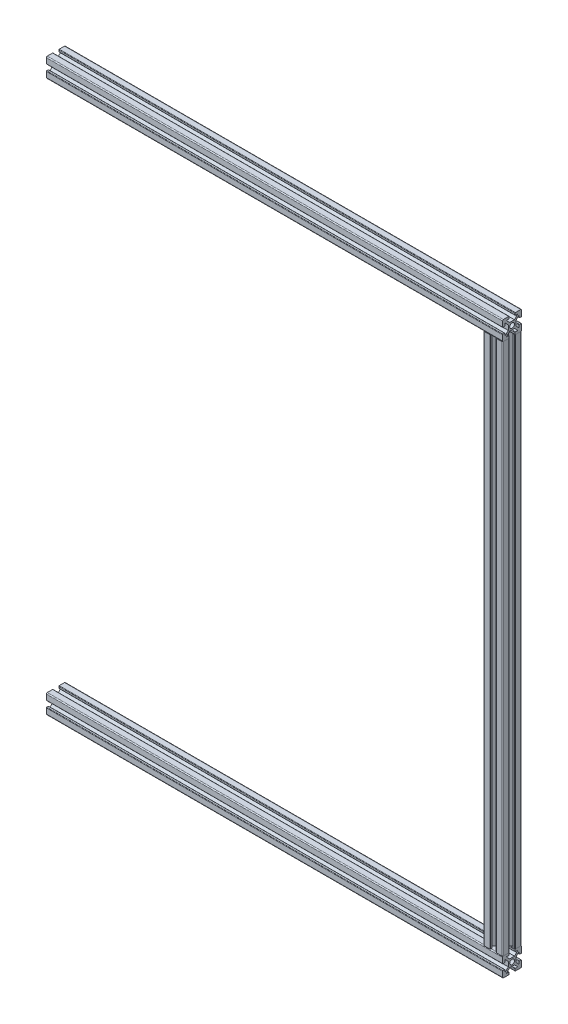
from build123d import *

# Parameters (mm, degrees)
SKETCH11_R                              = 2.5
ALUMINIUM_PROF_ALUMINIUM_PROF_1_DEPTH   = 470
SKETCH11_ON_SEGMENT_2_R                 = 2.5
ALUMINIUM_PROF_ALUMINIUM_PROF_1_2_DEPTH = 580
SKETCH11_ON_SEGMENT_3_R                 = 2.5
ALUMINIUM_PROF_ALUMINIUM_PROF_1_3_DEPTH = 470
PART_START                              = 470
PART_RUN_ON_DEPTH                       = 11.535534
BODY_3_RUN_ON_DEPTH                     = 11.535534


with BuildPart() as part:
    # Sketch11 → Aluminium prof ALUMINIUM PROF(1) (new body)
    with BuildSketch(Plane(origin=(-195.421052632, 179.342105263, 0), x_dir=(0, 1, 0), z_dir=(1, 0, 0))):
        with BuildLine():
            Line((-2.5, 4), (2.5, 4))
            Line((2.5, 4), (6.035533906, 7.535533906))
            Line((6.035533906, 7.535533906), (3.535533906, 7.535533906))
            ThreePointArc((3.535533906, 7.535533906), (3.181980515, 7.681980515), (3.035533906, 8.035533906))
            Line((3.035533906, 8.035533906), (3.035533906, 9.535533906))
            ThreePointArc((3.035533906, 9.535533906), (3.181980515, 9.889087297), (3.535533906, 10.035533906))
            Line((3.535533906, 10.035533906), (9.035533906, 10.035533906))
            ThreePointArc((9.035533906, 10.035533906), (9.742640687, 9.742640687), (10.035533906, 9.035533906))
            Line((10.035533906, 9.035533906), (10.035533906, 3.535533906))
            ThreePointArc((10.035533906, 3.535533906), (9.889087297, 3.181980515), (9.535533906, 3.035533906))
            Line((9.535533906, 3.035533906), (8.035533906, 3.035533906))
            ThreePointArc((8.035533906, 3.035533906), (7.681980515, 3.181980515), (7.535533906, 3.535533906))
            Line((7.535533906, 3.535533906), (7.535533906, 6.035533906))
            Line((7.535533906, 6.035533906), (4, 2.5))
            Line((4, 2.5), (4, -2.5))
            Line((4, -2.5), (7.535533906, -6.035533906))
            Line((7.535533906, -6.035533906), (7.535533906, -3.535533906))
            ThreePointArc((7.535533906, -3.535533906), (7.681980515, -3.181980515), (8.035533906, -3.035533906))
            Line((8.035533906, -3.035533906), (9.535533906, -3.035533906))
            ThreePointArc((9.535533906, -3.035533906), (9.889087297, -3.181980515), (10.035533906, -3.535533906))
            Line((10.035533906, -3.535533906), (10.035533906, -9.035533906))
            ThreePointArc((10.035533906, -9.035533906), (9.742640687, -9.742640687), (9.035533906, -10.035533906))
            Line((9.035533906, -10.035533906), (3.535533906, -10.035533906))
            ThreePointArc((3.535533906, -10.035533906), (3.181980515, -9.889087297), (3.035533906, -9.535533906))
            Line((3.035533906, -9.535533906), (3.035533906, -8.035533906))
            ThreePointArc((3.035533906, -8.035533906), (3.181980515, -7.681980515), (3.535533906, -7.535533906))
            Line((3.535533906, -7.535533906), (6.035533906, -7.535533906))
            Line((6.035533906, -7.535533906), (2.5, -4))
            Line((2.5, -4), (-2.5, -4))
            Line((-2.5, -4), (-6.035533906, -7.535533906))
            Line((-6.035533906, -7.535533906), (-3.535533906, -7.535533906))
            ThreePointArc((-3.535533906, -7.535533906), (-3.181980515, -7.681980515), (-3.035533906, -8.035533906))
            Line((-3.035533906, -8.035533906), (-3.035533906, -9.535533906))
            ThreePointArc((-3.035533906, -9.535533906), (-3.181980515, -9.889087297), (-3.535533906, -10.035533906))
            Line((-3.535533906, -10.035533906), (-9.035533906, -10.035533906))
            ThreePointArc((-9.035533906, -10.035533906), (-9.742640687, -9.742640687), (-10.035533906, -9.035533906))
            Line((-10.035533906, -9.035533906), (-10.035533906, -3.535533906))
            ThreePointArc((-10.035533906, -3.535533906), (-9.889087297, -3.181980515), (-9.535533906, -3.035533906))
            Line((-9.535533906, -3.035533906), (-8.035533906, -3.035533906))
            ThreePointArc((-8.035533906, -3.035533906), (-7.681980515, -3.181980515), (-7.535533906, -3.535533906))
            Line((-7.535533906, -3.535533906), (-7.535533906, -6.035533906))
            Line((-7.535533906, -6.035533906), (-4, -2.5))
            Line((-4, -2.5), (-4, 2.5))
            Line((-4, 2.5), (-7.535533906, 6.035533906))
            Line((-7.535533906, 6.035533906), (-7.535533906, 3.535533906))
            ThreePointArc((-7.535533906, 3.535533906), (-7.681980515, 3.181980515), (-8.035533906, 3.035533906))
            Line((-8.035533906, 3.035533906), (-9.535533906, 3.035533906))
            ThreePointArc((-9.535533906, 3.035533906), (-9.889087297, 3.181980515), (-10.035533906, 3.535533906))
            Line((-10.035533906, 3.535533906), (-10.035533906, 9.035533906))
            ThreePointArc((-10.035533906, 9.035533906), (-9.742640687, 9.742640687), (-9.035533906, 10.035533906))
            Line((-9.035533906, 10.035533906), (-3.535533906, 10.035533906))
            ThreePointArc((-3.535533906, 10.035533906), (-3.181980515, 9.889087297), (-3.035533906, 9.535533906))
            Line((-3.035533906, 9.535533906), (-3.035533906, 8.035533906))
            ThreePointArc((-3.035533906, 8.035533906), (-3.181980515, 7.681980515), (-3.535533906, 7.535533906))
            Line((-3.535533906, 7.535533906), (-6.035533906, 7.535533906))
            Line((-6.035533906, 7.535533906), (-2.5, 4))
        make_face()
        Circle(SKETCH11_R, mode=Mode.SUBTRACT)
    extrude(amount=ALUMINIUM_PROF_ALUMINIUM_PROF_1_DEPTH)

    # Sketch11 → part run on (add)
    with BuildSketch(Plane(origin=(-195.421052632, 179.342105263, 0), x_dir=(0, 1, 0), z_dir=(1, 0, 0)).offset(PART_START)):
        with BuildLine():
            Line((-2.5, 4), (2.5, 4))
            Line((2.5, 4), (6.035533906, 7.535533906))
            Line((6.035533906, 7.535533906), (3.535533906, 7.535533906))
            ThreePointArc((3.535533906, 7.535533906), (3.181980515, 7.681980515), (3.035533906, 8.035533906))
            Line((3.035533906, 8.035533906), (3.035533906, 9.535533906))
            ThreePointArc((3.035533906, 9.535533906), (3.181980515, 9.889087297), (3.535533906, 10.035533906))
            Line((3.535533906, 10.035533906), (9.035533906, 10.035533906))
            ThreePointArc((9.035533906, 10.035533906), (9.742640687, 9.742640687), (10.035533906, 9.035533906))
            Line((10.035533906, 9.035533906), (10.035533906, 3.535533906))
            ThreePointArc((10.035533906, 3.535533906), (9.889087297, 3.181980515), (9.535533906, 3.035533906))
            Line((9.535533906, 3.035533906), (8.035533906, 3.035533906))
            ThreePointArc((8.035533906, 3.035533906), (7.681980515, 3.181980515), (7.535533906, 3.535533906))
            Line((7.535533906, 3.535533906), (7.535533906, 6.035533906))
            Line((7.535533906, 6.035533906), (4, 2.5))
            Line((4, 2.5), (4, -2.5))
            Line((4, -2.5), (7.535533906, -6.035533906))
            Line((7.535533906, -6.035533906), (7.535533906, -3.535533906))
            ThreePointArc((7.535533906, -3.535533906), (7.681980515, -3.181980515), (8.035533906, -3.035533906))
            Line((8.035533906, -3.035533906), (9.535533906, -3.035533906))
            ThreePointArc((9.535533906, -3.035533906), (9.889087297, -3.181980515), (10.035533906, -3.535533906))
            Line((10.035533906, -3.535533906), (10.035533906, -9.035533906))
            ThreePointArc((10.035533906, -9.035533906), (9.742640687, -9.742640687), (9.035533906, -10.035533906))
            Line((9.035533906, -10.035533906), (3.535533906, -10.035533906))
            ThreePointArc((3.535533906, -10.035533906), (3.181980515, -9.889087297), (3.035533906, -9.535533906))
            Line((3.035533906, -9.535533906), (3.035533906, -8.035533906))
            ThreePointArc((3.035533906, -8.035533906), (3.181980515, -7.681980515), (3.535533906, -7.535533906))
            Line((3.535533906, -7.535533906), (6.035533906, -7.535533906))
            Line((6.035533906, -7.535533906), (2.5, -4))
            Line((2.5, -4), (-2.5, -4))
            Line((-2.5, -4), (-6.035533906, -7.535533906))
            Line((-6.035533906, -7.535533906), (-3.535533906, -7.535533906))
            ThreePointArc((-3.535533906, -7.535533906), (-3.181980515, -7.681980515), (-3.035533906, -8.035533906))
            Line((-3.035533906, -8.035533906), (-3.035533906, -9.535533906))
            ThreePointArc((-3.035533906, -9.535533906), (-3.181980515, -9.889087297), (-3.535533906, -10.035533906))
            Line((-3.535533906, -10.035533906), (-9.035533906, -10.035533906))
            ThreePointArc((-9.035533906, -10.035533906), (-9.742640687, -9.742640687), (-10.035533906, -9.035533906))
            Line((-10.035533906, -9.035533906), (-10.035533906, -3.535533906))
            ThreePointArc((-10.035533906, -3.535533906), (-9.889087297, -3.181980515), (-9.535533906, -3.035533906))
            Line((-9.535533906, -3.035533906), (-8.035533906, -3.035533906))
            ThreePointArc((-8.035533906, -3.035533906), (-7.681980515, -3.181980515), (-7.535533906, -3.535533906))
            Line((-7.535533906, -3.535533906), (-7.535533906, -6.035533906))
            Line((-7.535533906, -6.035533906), (-4, -2.5))
            Line((-4, -2.5), (-4, 2.5))
            Line((-4, 2.5), (-7.535533906, 6.035533906))
            Line((-7.535533906, 6.035533906), (-7.535533906, 3.535533906))
            ThreePointArc((-7.535533906, 3.535533906), (-7.681980515, 3.181980515), (-8.035533906, 3.035533906))
            Line((-8.035533906, 3.035533906), (-9.535533906, 3.035533906))
            ThreePointArc((-9.535533906, 3.035533906), (-9.889087297, 3.181980515), (-10.035533906, 3.535533906))
            Line((-10.035533906, 3.535533906), (-10.035533906, 9.035533906))
            ThreePointArc((-10.035533906, 9.035533906), (-9.742640687, 9.742640687), (-9.035533906, 10.035533906))
            Line((-9.035533906, 10.035533906), (-3.535533906, 10.035533906))
            ThreePointArc((-3.535533906, 10.035533906), (-3.181980515, 9.889087297), (-3.035533906, 9.535533906))
            Line((-3.035533906, 9.535533906), (-3.035533906, 8.035533906))
            ThreePointArc((-3.035533906, 8.035533906), (-3.181980515, 7.681980515), (-3.535533906, 7.535533906))
            Line((-3.535533906, 7.535533906), (-6.035533906, 7.535533906))
            Line((-6.035533906, 7.535533906), (-2.5, 4))
        make_face()
        Circle(SKETCH11_R, mode=Mode.SUBTRACT)
    extrude(amount=PART_RUN_ON_DEPTH)

    # Trim_Extend1 6
    split(bisect_by=Plane(origin=(284.614481274, -110.657894737, 6.285533906), x_dir=(0, -1, 0), z_dir=(-1, 0, 0)), keep=Keep.TOP)


with BuildPart() as body_2:
    # Sketch11 on segment 2 (carried to segment 2) → Aluminium prof ALUMINIUM PROF_1 2 (new body)
    with BuildSketch(Plane(origin=(274.578947368, 179.342105263, 0), x_dir=(1, 0, 0), z_dir=(0, -1, 0))):
        with BuildLine():
            Line((-2.5, 4), (2.5, 4))
            Line((2.5, 4), (6.035533906, 7.535533906))
            Line((6.035533906, 7.535533906), (3.535533906, 7.535533906))
            ThreePointArc((3.535533906, 7.535533906), (3.181980515, 7.681980515), (3.035533906, 8.035533906))
            Line((3.035533906, 8.035533906), (3.035533906, 9.535533906))
            ThreePointArc((3.035533906, 9.535533906), (3.181980515, 9.889087297), (3.535533906, 10.035533906))
            Line((3.535533906, 10.035533906), (9.035533906, 10.035533906))
            ThreePointArc((9.035533906, 10.035533906), (9.742640687, 9.742640687), (10.035533906, 9.035533906))
            Line((10.035533906, 9.035533906), (10.035533906, 3.535533906))
            ThreePointArc((10.035533906, 3.535533906), (9.889087297, 3.181980515), (9.535533906, 3.035533906))
            Line((9.535533906, 3.035533906), (8.035533906, 3.035533906))
            ThreePointArc((8.035533906, 3.035533906), (7.681980515, 3.181980515), (7.535533906, 3.535533906))
            Line((7.535533906, 3.535533906), (7.535533906, 6.035533906))
            Line((7.535533906, 6.035533906), (4, 2.5))
            Line((4, 2.5), (4, -2.5))
            Line((4, -2.5), (7.535533906, -6.035533906))
            Line((7.535533906, -6.035533906), (7.535533906, -3.535533906))
            ThreePointArc((7.535533906, -3.535533906), (7.681980515, -3.181980515), (8.035533906, -3.035533906))
            Line((8.035533906, -3.035533906), (9.535533906, -3.035533906))
            ThreePointArc((9.535533906, -3.035533906), (9.889087297, -3.181980515), (10.035533906, -3.535533906))
            Line((10.035533906, -3.535533906), (10.035533906, -9.035533906))
            ThreePointArc((10.035533906, -9.035533906), (9.742640687, -9.742640687), (9.035533906, -10.035533906))
            Line((9.035533906, -10.035533906), (3.535533906, -10.035533906))
            ThreePointArc((3.535533906, -10.035533906), (3.181980515, -9.889087297), (3.035533906, -9.535533906))
            Line((3.035533906, -9.535533906), (3.035533906, -8.035533906))
            ThreePointArc((3.035533906, -8.035533906), (3.181980515, -7.681980515), (3.535533906, -7.535533906))
            Line((3.535533906, -7.535533906), (6.035533906, -7.535533906))
            Line((6.035533906, -7.535533906), (2.5, -4))
            Line((2.5, -4), (-2.5, -4))
            Line((-2.5, -4), (-6.035533906, -7.535533906))
            Line((-6.035533906, -7.535533906), (-3.535533906, -7.535533906))
            ThreePointArc((-3.535533906, -7.535533906), (-3.181980515, -7.681980515), (-3.035533906, -8.035533906))
            Line((-3.035533906, -8.035533906), (-3.035533906, -9.535533906))
            ThreePointArc((-3.035533906, -9.535533906), (-3.181980515, -9.889087297), (-3.535533906, -10.035533906))
            Line((-3.535533906, -10.035533906), (-9.035533906, -10.035533906))
            ThreePointArc((-9.035533906, -10.035533906), (-9.742640687, -9.742640687), (-10.035533906, -9.035533906))
            Line((-10.035533906, -9.035533906), (-10.035533906, -3.535533906))
            ThreePointArc((-10.035533906, -3.535533906), (-9.889087297, -3.181980515), (-9.535533906, -3.035533906))
            Line((-9.535533906, -3.035533906), (-8.035533906, -3.035533906))
            ThreePointArc((-8.035533906, -3.035533906), (-7.681980515, -3.181980515), (-7.535533906, -3.535533906))
            Line((-7.535533906, -3.535533906), (-7.535533906, -6.035533906))
            Line((-7.535533906, -6.035533906), (-4, -2.5))
            Line((-4, -2.5), (-4, 2.5))
            Line((-4, 2.5), (-7.535533906, 6.035533906))
            Line((-7.535533906, 6.035533906), (-7.535533906, 3.535533906))
            ThreePointArc((-7.535533906, 3.535533906), (-7.681980515, 3.181980515), (-8.035533906, 3.035533906))
            Line((-8.035533906, 3.035533906), (-9.535533906, 3.035533906))
            ThreePointArc((-9.535533906, 3.035533906), (-9.889087297, 3.181980515), (-10.035533906, 3.535533906))
            Line((-10.035533906, 3.535533906), (-10.035533906, 9.035533906))
            ThreePointArc((-10.035533906, 9.035533906), (-9.742640687, 9.742640687), (-9.035533906, 10.035533906))
            Line((-9.035533906, 10.035533906), (-3.535533906, 10.035533906))
            ThreePointArc((-3.535533906, 10.035533906), (-3.181980515, 9.889087297), (-3.035533906, 9.535533906))
            Line((-3.035533906, 9.535533906), (-3.035533906, 8.035533906))
            ThreePointArc((-3.035533906, 8.035533906), (-3.181980515, 7.681980515), (-3.535533906, 7.535533906))
            Line((-3.535533906, 7.535533906), (-6.035533906, 7.535533906))
            Line((-6.035533906, 7.535533906), (-2.5, 4))
        make_face()
        Circle(SKETCH11_ON_SEGMENT_2_R, mode=Mode.SUBTRACT)
    extrude(amount=ALUMINIUM_PROF_ALUMINIUM_PROF_1_2_DEPTH)

    # Trim_Extend1 3
    split(bisect_by=Plane(origin=(39.578947368, 169.306571357, -6.285533906), x_dir=(1, 0, 0), z_dir=(0, -1, 0)), keep=Keep.TOP)

    # Trim_Extend2 7
    split(bisect_by=Plane(origin=(39.578947368, -390.622360831, -6.285533906), x_dir=(-1, 0, 0), z_dir=(0, 1, 0)), keep=Keep.TOP)


with BuildPart() as body_3:
    # Sketch11 on segment 3 (carried to segment 3) → Aluminium prof ALUMINIUM PROF_1 3 (new body)
    with BuildSketch(Plane(origin=(274.578947368, -400.657894737, 0), x_dir=(0, -1, 0), z_dir=(-1, 0, 0))):
        with BuildLine():
            Line((-2.5, 4), (2.5, 4))
            Line((2.5, 4), (6.035533906, 7.535533906))
            Line((6.035533906, 7.535533906), (3.535533906, 7.535533906))
            ThreePointArc((3.535533906, 7.535533906), (3.181980515, 7.681980515), (3.035533906, 8.035533906))
            Line((3.035533906, 8.035533906), (3.035533906, 9.535533906))
            ThreePointArc((3.035533906, 9.535533906), (3.181980515, 9.889087297), (3.535533906, 10.035533906))
            Line((3.535533906, 10.035533906), (9.035533906, 10.035533906))
            ThreePointArc((9.035533906, 10.035533906), (9.742640687, 9.742640687), (10.035533906, 9.035533906))
            Line((10.035533906, 9.035533906), (10.035533906, 3.535533906))
            ThreePointArc((10.035533906, 3.535533906), (9.889087297, 3.181980515), (9.535533906, 3.035533906))
            Line((9.535533906, 3.035533906), (8.035533906, 3.035533906))
            ThreePointArc((8.035533906, 3.035533906), (7.681980515, 3.181980515), (7.535533906, 3.535533906))
            Line((7.535533906, 3.535533906), (7.535533906, 6.035533906))
            Line((7.535533906, 6.035533906), (4, 2.5))
            Line((4, 2.5), (4, -2.5))
            Line((4, -2.5), (7.535533906, -6.035533906))
            Line((7.535533906, -6.035533906), (7.535533906, -3.535533906))
            ThreePointArc((7.535533906, -3.535533906), (7.681980515, -3.181980515), (8.035533906, -3.035533906))
            Line((8.035533906, -3.035533906), (9.535533906, -3.035533906))
            ThreePointArc((9.535533906, -3.035533906), (9.889087297, -3.181980515), (10.035533906, -3.535533906))
            Line((10.035533906, -3.535533906), (10.035533906, -9.035533906))
            ThreePointArc((10.035533906, -9.035533906), (9.742640687, -9.742640687), (9.035533906, -10.035533906))
            Line((9.035533906, -10.035533906), (3.535533906, -10.035533906))
            ThreePointArc((3.535533906, -10.035533906), (3.181980515, -9.889087297), (3.035533906, -9.535533906))
            Line((3.035533906, -9.535533906), (3.035533906, -8.035533906))
            ThreePointArc((3.035533906, -8.035533906), (3.181980515, -7.681980515), (3.535533906, -7.535533906))
            Line((3.535533906, -7.535533906), (6.035533906, -7.535533906))
            Line((6.035533906, -7.535533906), (2.5, -4))
            Line((2.5, -4), (-2.5, -4))
            Line((-2.5, -4), (-6.035533906, -7.535533906))
            Line((-6.035533906, -7.535533906), (-3.535533906, -7.535533906))
            ThreePointArc((-3.535533906, -7.535533906), (-3.181980515, -7.681980515), (-3.035533906, -8.035533906))
            Line((-3.035533906, -8.035533906), (-3.035533906, -9.535533906))
            ThreePointArc((-3.035533906, -9.535533906), (-3.181980515, -9.889087297), (-3.535533906, -10.035533906))
            Line((-3.535533906, -10.035533906), (-9.035533906, -10.035533906))
            ThreePointArc((-9.035533906, -10.035533906), (-9.742640687, -9.742640687), (-10.035533906, -9.035533906))
            Line((-10.035533906, -9.035533906), (-10.035533906, -3.535533906))
            ThreePointArc((-10.035533906, -3.535533906), (-9.889087297, -3.181980515), (-9.535533906, -3.035533906))
            Line((-9.535533906, -3.035533906), (-8.035533906, -3.035533906))
            ThreePointArc((-8.035533906, -3.035533906), (-7.681980515, -3.181980515), (-7.535533906, -3.535533906))
            Line((-7.535533906, -3.535533906), (-7.535533906, -6.035533906))
            Line((-7.535533906, -6.035533906), (-4, -2.5))
            Line((-4, -2.5), (-4, 2.5))
            Line((-4, 2.5), (-7.535533906, 6.035533906))
            Line((-7.535533906, 6.035533906), (-7.535533906, 3.535533906))
            ThreePointArc((-7.535533906, 3.535533906), (-7.681980515, 3.181980515), (-8.035533906, 3.035533906))
            Line((-8.035533906, 3.035533906), (-9.535533906, 3.035533906))
            ThreePointArc((-9.535533906, 3.035533906), (-9.889087297, 3.181980515), (-10.035533906, 3.535533906))
            Line((-10.035533906, 3.535533906), (-10.035533906, 9.035533906))
            ThreePointArc((-10.035533906, 9.035533906), (-9.742640687, 9.742640687), (-9.035533906, 10.035533906))
            Line((-9.035533906, 10.035533906), (-3.535533906, 10.035533906))
            ThreePointArc((-3.535533906, 10.035533906), (-3.181980515, 9.889087297), (-3.035533906, 9.535533906))
            Line((-3.035533906, 9.535533906), (-3.035533906, 8.035533906))
            ThreePointArc((-3.035533906, 8.035533906), (-3.181980515, 7.681980515), (-3.535533906, 7.535533906))
            Line((-3.535533906, 7.535533906), (-6.035533906, 7.535533906))
            Line((-6.035533906, 7.535533906), (-2.5, 4))
        make_face()
        Circle(SKETCH11_ON_SEGMENT_3_R, mode=Mode.SUBTRACT)
    extrude(amount=ALUMINIUM_PROF_ALUMINIUM_PROF_1_3_DEPTH)

    # Sketch11 on segment 3 (carried to segment 3) → body 3 run on (add)
    with BuildSketch(Plane(origin=(274.578947368, -400.657894737, 0), x_dir=(0, -1, 0), z_dir=(-1, 0, 0))):
        with BuildLine():
            Line((-2.5, 4), (2.5, 4))
            Line((2.5, 4), (6.035533906, 7.535533906))
            Line((6.035533906, 7.535533906), (3.535533906, 7.535533906))
            ThreePointArc((3.535533906, 7.535533906), (3.181980515, 7.681980515), (3.035533906, 8.035533906))
            Line((3.035533906, 8.035533906), (3.035533906, 9.535533906))
            ThreePointArc((3.035533906, 9.535533906), (3.181980515, 9.889087297), (3.535533906, 10.035533906))
            Line((3.535533906, 10.035533906), (9.035533906, 10.035533906))
            ThreePointArc((9.035533906, 10.035533906), (9.742640687, 9.742640687), (10.035533906, 9.035533906))
            Line((10.035533906, 9.035533906), (10.035533906, 3.535533906))
            ThreePointArc((10.035533906, 3.535533906), (9.889087297, 3.181980515), (9.535533906, 3.035533906))
            Line((9.535533906, 3.035533906), (8.035533906, 3.035533906))
            ThreePointArc((8.035533906, 3.035533906), (7.681980515, 3.181980515), (7.535533906, 3.535533906))
            Line((7.535533906, 3.535533906), (7.535533906, 6.035533906))
            Line((7.535533906, 6.035533906), (4, 2.5))
            Line((4, 2.5), (4, -2.5))
            Line((4, -2.5), (7.535533906, -6.035533906))
            Line((7.535533906, -6.035533906), (7.535533906, -3.535533906))
            ThreePointArc((7.535533906, -3.535533906), (7.681980515, -3.181980515), (8.035533906, -3.035533906))
            Line((8.035533906, -3.035533906), (9.535533906, -3.035533906))
            ThreePointArc((9.535533906, -3.035533906), (9.889087297, -3.181980515), (10.035533906, -3.535533906))
            Line((10.035533906, -3.535533906), (10.035533906, -9.035533906))
            ThreePointArc((10.035533906, -9.035533906), (9.742640687, -9.742640687), (9.035533906, -10.035533906))
            Line((9.035533906, -10.035533906), (3.535533906, -10.035533906))
            ThreePointArc((3.535533906, -10.035533906), (3.181980515, -9.889087297), (3.035533906, -9.535533906))
            Line((3.035533906, -9.535533906), (3.035533906, -8.035533906))
            ThreePointArc((3.035533906, -8.035533906), (3.181980515, -7.681980515), (3.535533906, -7.535533906))
            Line((3.535533906, -7.535533906), (6.035533906, -7.535533906))
            Line((6.035533906, -7.535533906), (2.5, -4))
            Line((2.5, -4), (-2.5, -4))
            Line((-2.5, -4), (-6.035533906, -7.535533906))
            Line((-6.035533906, -7.535533906), (-3.535533906, -7.535533906))
            ThreePointArc((-3.535533906, -7.535533906), (-3.181980515, -7.681980515), (-3.035533906, -8.035533906))
            Line((-3.035533906, -8.035533906), (-3.035533906, -9.535533906))
            ThreePointArc((-3.035533906, -9.535533906), (-3.181980515, -9.889087297), (-3.535533906, -10.035533906))
            Line((-3.535533906, -10.035533906), (-9.035533906, -10.035533906))
            ThreePointArc((-9.035533906, -10.035533906), (-9.742640687, -9.742640687), (-10.035533906, -9.035533906))
            Line((-10.035533906, -9.035533906), (-10.035533906, -3.535533906))
            ThreePointArc((-10.035533906, -3.535533906), (-9.889087297, -3.181980515), (-9.535533906, -3.035533906))
            Line((-9.535533906, -3.035533906), (-8.035533906, -3.035533906))
            ThreePointArc((-8.035533906, -3.035533906), (-7.681980515, -3.181980515), (-7.535533906, -3.535533906))
            Line((-7.535533906, -3.535533906), (-7.535533906, -6.035533906))
            Line((-7.535533906, -6.035533906), (-4, -2.5))
            Line((-4, -2.5), (-4, 2.5))
            Line((-4, 2.5), (-7.535533906, 6.035533906))
            Line((-7.535533906, 6.035533906), (-7.535533906, 3.535533906))
            ThreePointArc((-7.535533906, 3.535533906), (-7.681980515, 3.181980515), (-8.035533906, 3.035533906))
            Line((-8.035533906, 3.035533906), (-9.535533906, 3.035533906))
            ThreePointArc((-9.535533906, 3.035533906), (-9.889087297, 3.181980515), (-10.035533906, 3.535533906))
            Line((-10.035533906, 3.535533906), (-10.035533906, 9.035533906))
            ThreePointArc((-10.035533906, 9.035533906), (-9.742640687, 9.742640687), (-9.035533906, 10.035533906))
            Line((-9.035533906, 10.035533906), (-3.535533906, 10.035533906))
            ThreePointArc((-3.535533906, 10.035533906), (-3.181980515, 9.889087297), (-3.035533906, 9.535533906))
            Line((-3.035533906, 9.535533906), (-3.035533906, 8.035533906))
            ThreePointArc((-3.035533906, 8.035533906), (-3.181980515, 7.681980515), (-3.535533906, 7.535533906))
            Line((-3.535533906, 7.535533906), (-6.035533906, 7.535533906))
            Line((-6.035533906, 7.535533906), (-2.5, 4))
        make_face()
        Circle(SKETCH11_ON_SEGMENT_3_R, mode=Mode.SUBTRACT)
    extrude(amount=-BODY_3_RUN_ON_DEPTH)

    # Trim_Extend2 8
    split(bisect_by=Plane(origin=(284.614481274, -115.67566169, 6.285533906), x_dir=(0, -1, 0), z_dir=(-1, 0, 0)), keep=Keep.TOP)


solid = Compound([part.part, body_2.part, body_3.part])
